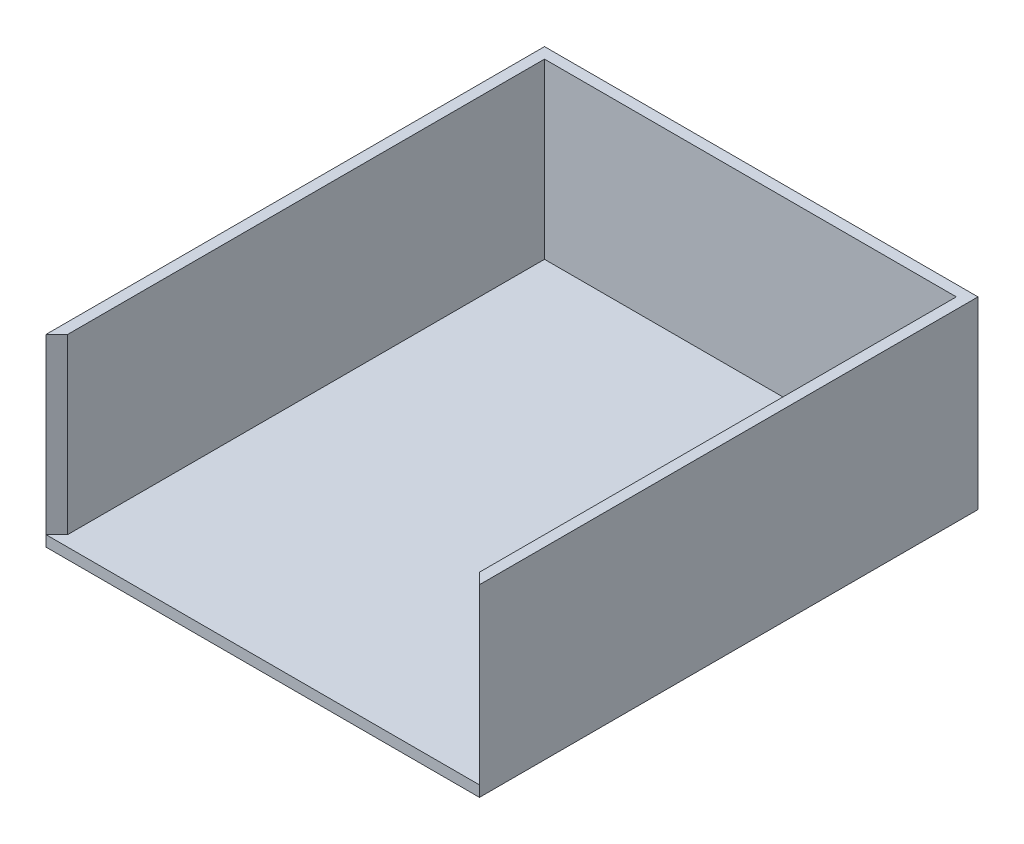
from build123d import *

# Parameters (mm, degrees)
SKETCH1_W           = 200
SKETCH1_H           = 230
BOSS_EXTRUDE1_DEPTH = 5
BOSS_EXTRUDE2_DEPTH = 80


with BuildPart() as part:
    # Sketch1 → Boss-Extrude1 (new body)
    with BuildSketch(Plane(origin=(0, 0, 0), x_dir=(1, 0, 0), z_dir=(0, 1, 0))):
        Rectangle(SKETCH1_W, SKETCH1_H)
    extrude(amount=BOSS_EXTRUDE1_DEPTH)

    # Sketch2 → Boss-Extrude2 (add)
    with BuildSketch(Plane(origin=(0, 5, 0), x_dir=(1, 0, 0), z_dir=(0, 1, 0))):
        Polygon((100, -115), (100, 115), (-100, 115), (-100, -115), (-95, -110), (-95, 110), (95, 110), (95, -110), align=None)
    extrude(amount=BOSS_EXTRUDE2_DEPTH)


solid = part.part
